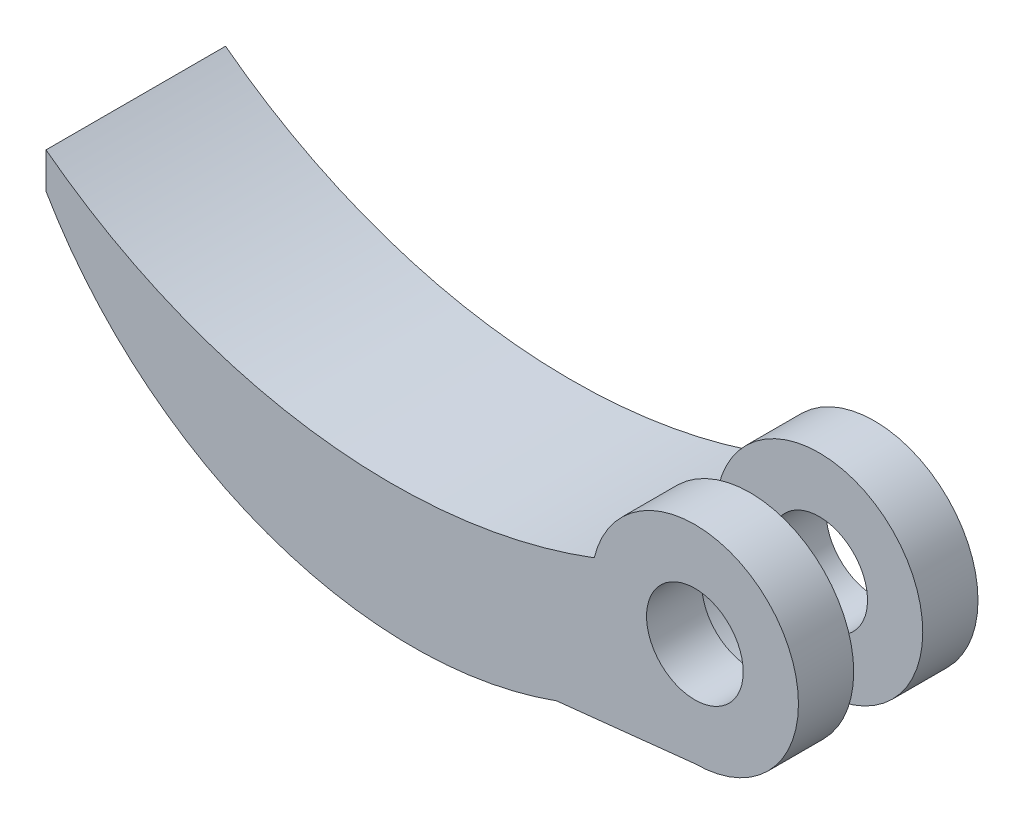
from build123d import *

# Parameters (mm, degrees)
CROQUIS1_R              = 7.5
CROQUIS1_R_2            = 3.5
SALIENTE_EXTRUIR1_DEPTH = 4
CROQUIS2_R              = 2.193779366
SALIENTE_EXTRUIR2_DEPTH = 5
CROQUIS3_R              = 7.5
CROQUIS3_R_2            = 3.5
SALIENTE_EXTRUIR3_DEPTH = 4
CROQUIS4_R              = 2.193779366
CORTAR_EXTRUIR1_DEPTH   = 14
SALIENTE_EXTRUIR4_DEPTH = 13


with BuildPart() as part:
    # Croquis1 → Saliente-Extruir1 (new body)
    with BuildSketch(Plane.XY):
        Circle(CROQUIS1_R)
        Circle(CROQUIS1_R_2, mode=Mode.SUBTRACT)
    extrude(amount=SALIENTE_EXTRUIR1_DEPTH)



with BuildPart() as body_2:
    # Croquis2 → Saliente-Extruir2 (new body)
    with BuildSketch(Plane(origin=(0, 0, 0), x_dir=(-1, 0, 0), z_dir=(0, 0, -1))):
        Circle(CROQUIS2_R)
    extrude(amount=SALIENTE_EXTRUIR2_DEPTH)

    # Croquis4 → Cortar-Extruir1 (cut)
    with BuildSketch(Plane(origin=(0, 0, -5), x_dir=(-1, 0, 0), z_dir=(0, 0, -1))):
        Circle(CROQUIS4_R)
    extrude(amount=-CORTAR_EXTRUIR1_DEPTH, mode=Mode.SUBTRACT)


with BuildPart() as body_3:
    # Croquis3 → Saliente-Extruir3 (new body)
    with BuildSketch(Plane(origin=(0, 0, -5), x_dir=(-1, 0, 0), z_dir=(0, 0, -1))):
        Circle(CROQUIS3_R)
        Circle(CROQUIS3_R_2, mode=Mode.SUBTRACT)
    extrude(amount=SALIENTE_EXTRUIR3_DEPTH)


with BuildPart() as part_1:
    add(part.part)

    add(body_3.part)  # Saliente-Extruir4 merges body 3
    # Croquis5 → Saliente-Extruir4 (add)
    with BuildSketch(Plane.XY.offset(4)):
        with BuildLine():
            Line((-10.009282788, -8.566914266), (0, -7.5))
            ThreePointArc((0, -7.5), (-5.895156044, -4.636500319), (-7.288771435, 1.76743061))
            ThreePointArc((-7.288771435, 1.76743061), (-27.875344012, -0.49038836), (-46.981845806, 7.5))
            Line((-46.981845806, 7.5), (-46.981845806, 4.90393409))
            ThreePointArc((-46.981845806, 4.90393409), (-30.939741801, -8.539865418), (-10.009282788, -8.566914266))
        make_face()
    extrude(amount=-SALIENTE_EXTRUIR4_DEPTH)


solid = part_1.part
